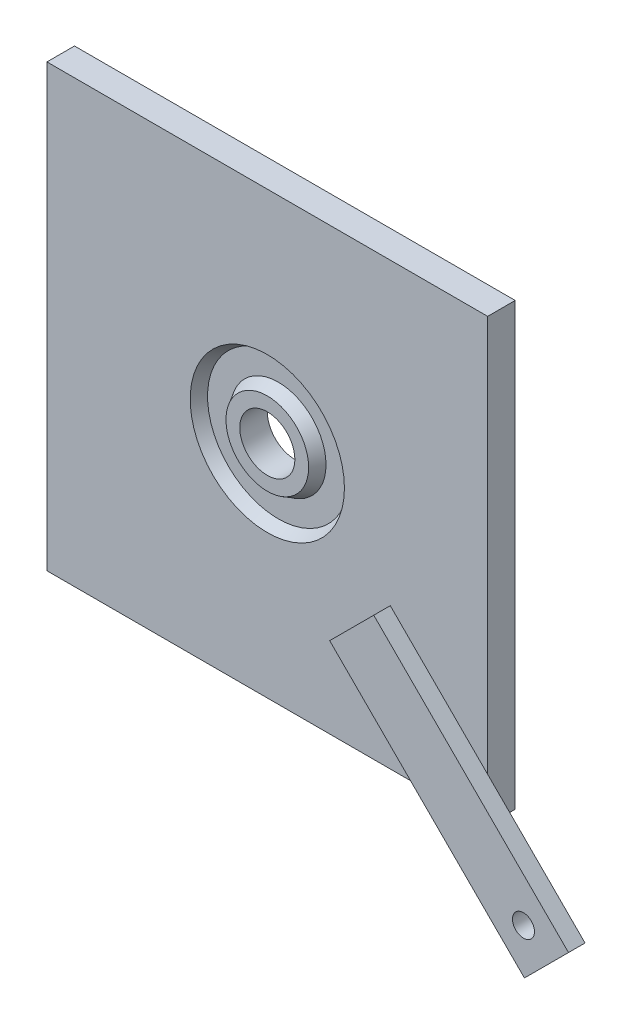
from build123d import *

# Parameters (mm, degrees)
SKETCH1_W           = 80
SKETCH1_H           = 80
SKETCH1_R           = 5
BOSS_EXTRUDE1_DEPTH = 5
SKETCH2_R           = 14
SKETCH2_R_2         = 7.5
CUT_EXTRUDE1_DEPTH  = 2
CUT_EXTRUDE1_TAPER  = 30
SKETCH3_R           = 2
BOSS_EXTRUDE2_DEPTH = 3


with BuildPart() as part:
    # Sketch1 → Boss-Extrude1 (new body)
    with BuildSketch(Plane.XY):
        Rectangle(SKETCH1_W, SKETCH1_H)
        Circle(SKETCH1_R, mode=Mode.SUBTRACT)
    extrude(amount=BOSS_EXTRUDE1_DEPTH)

    # Sketch2 → Cut-Extrude1 (cut)
    with BuildSketch(Plane.XY.offset(5)):
        Circle(SKETCH2_R)
        Circle(SKETCH2_R_2, mode=Mode.SUBTRACT)
    extrude(amount=-CUT_EXTRUDE1_DEPTH, taper=CUT_EXTRUDE1_TAPER, mode=Mode.SUBTRACT)

    # Sketch3 → Boss-Extrude2 (add)
    with BuildSketch(Plane.XY.offset(5)):
        Polygon((49.67766953, -57.67766953), (14.32233047, -22.32233047), (22.32233047, -14.32233047), (57.67766953, -49.67766953), align=None)
        with Locations((49.497474683, -49.497474683)):
            Circle(SKETCH3_R, mode=Mode.SUBTRACT)
    extrude(amount=BOSS_EXTRUDE2_DEPTH)


solid = part.part
